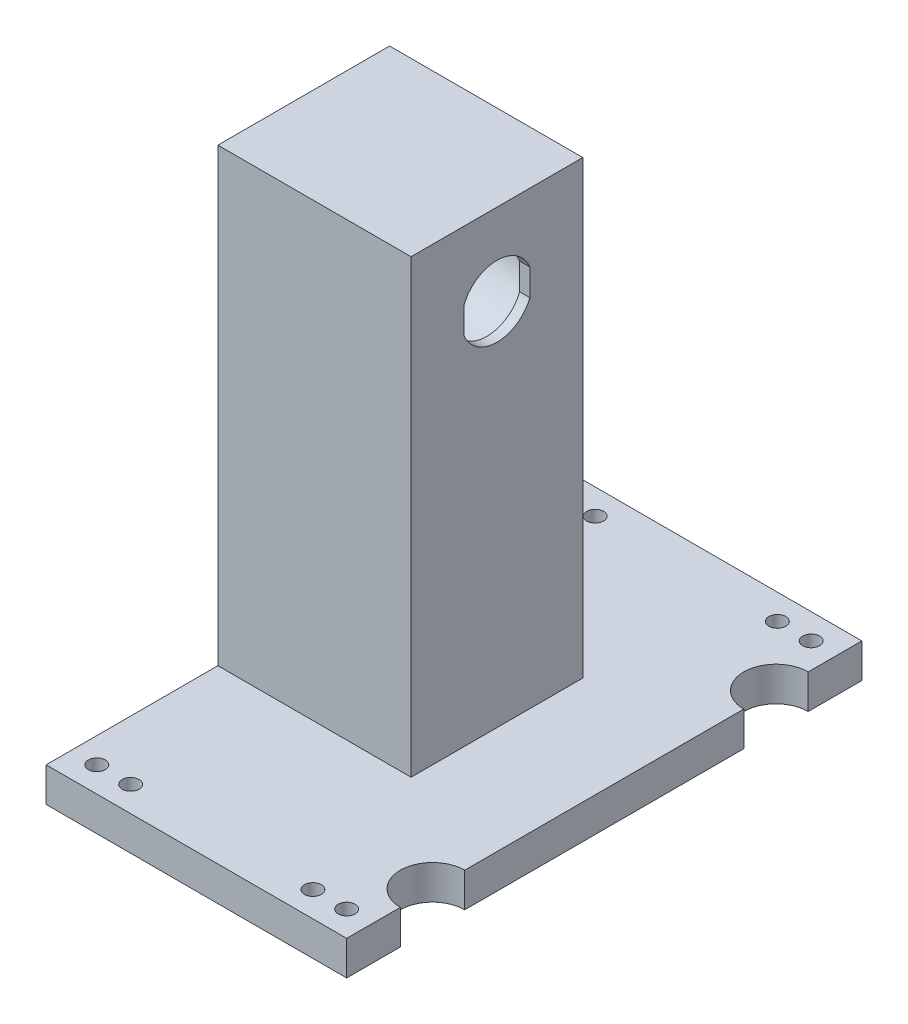
from build123d import *

# Parameters (mm, degrees)
SKETCH2_W           = 88.9
SKETCH2_H           = 152.4
BOSS_EXTRUDE1_DEPTH = 10.16
SKETCH5_W           = 57.15
SKETCH5_H           = 50.8
BOSS_EXTRUDE2_DEPTH = 133.35
SKETCH6_R           = 2.5
CUT_EXTRUDE1_DEPTH  = 11.16
SKETCH7_R           = 10.5
CUT_EXTRUDE2_DEPTH  = 58.15
SKETCH8_R           = 16.5
CUT_EXTRUDE3_DEPTH  = 54.15
SKETCH9_R           = 19.5
CUT_EXTRUDE4_DEPTH  = 16.51
BOSS_EXTRUDE3_DEPTH = 3
SKETCH12_R          = 9.525
CUT_EXTRUDE6_DEPTH  = 12.7


with BuildPart() as part:
    # Sketch2 → Boss-Extrude1 (new body)
    with BuildSketch(Plane(origin=(0, 0, 0), x_dir=(1, 0, 0), z_dir=(0, 1, 0))):
        with Locations((8.89, -19.614444444)):
            Rectangle(SKETCH2_W, SKETCH2_H)
    extrude(amount=BOSS_EXTRUDE1_DEPTH)

    # Sketch5 → Boss-Extrude2 (add)
    with BuildSketch(Plane(origin=(0, 10.16, 0), x_dir=(1, 0, 0), z_dir=(0, 1, 0))):
        with Locations((-6.985, -19.614444444)):
            Rectangle(SKETCH5_W, SKETCH5_H)
    extrude(amount=BOSS_EXTRUDE2_DEPTH)

    # Sketch6 → Cut-Extrude1 (cut, through all)
    with BuildSketch(Plane(origin=(0, 10.16, 0), x_dir=(1, 0, 0), z_dir=(0, 1, 0))):
        with Locations((35.84, -88.314444444)):
            Circle(SKETCH6_R)
        with Locations((45.84, -88.314444444)):
            Circle(SKETCH6_R)
        with Locations((-28.06, -88.314444444)):
            Circle(SKETCH6_R)
        with Locations((-18.06, -88.314444444)):
            Circle(SKETCH6_R)
        with Locations((-28.06, 49.085555556)):
            Circle(SKETCH6_R)
        with Locations((-18.06, 49.085555556)):
            Circle(SKETCH6_R)
        with Locations((35.84, 49.085555556)):
            Circle(SKETCH6_R)
        with Locations((45.84, 49.085555556)):
            Circle(SKETCH6_R)
    extrude(amount=-CUT_EXTRUDE1_DEPTH, mode=Mode.SUBTRACT)

    # Sketch7 → Cut-Extrude2 (cut, through all)
    with BuildSketch(Plane(origin=(21.59, 0, 0), x_dir=(0, 0, -1), z_dir=(1, 0, 0))):
        with Locations((-19.614444444, 119.38)):
            Circle(SKETCH7_R)
    extrude(amount=-CUT_EXTRUDE2_DEPTH, mode=Mode.SUBTRACT)

    # Sketch8 → Cut-Extrude3 (cut)
    with BuildSketch(Plane.ZY.offset(35.56)):
        with Locations((19.614444444, 119.38)):
            Circle(SKETCH8_R)
    extrude(amount=-CUT_EXTRUDE3_DEPTH, mode=Mode.SUBTRACT)

    # Sketch9 → Cut-Extrude4 (cut)
    with BuildSketch(Plane.ZY.offset(35.56)):
        with Locations((19.614444444, 119.38)):
            Circle(SKETCH9_R)
    extrude(amount=-CUT_EXTRUDE4_DEPTH, mode=Mode.SUBTRACT)

    # Sketch10 → Boss-Extrude3 (add)
    with BuildSketch(Plane(origin=(21.59, 0, 0), x_dir=(0, 0, -1), z_dir=(1, 0, 0))):
        with BuildLine():
            Line((-29.348407204, 123.317), (-29.348407204, 115.443))
            ThreePointArc((-29.348407204, 115.443), (-30.114444444, 119.38), (-29.348407204, 123.317))
        make_face()
        with BuildLine():
            Line((-9.880481685, 115.443), (-9.880481685, 123.317))
            ThreePointArc((-9.880481685, 123.317), (-9.114444444, 119.38), (-9.880481685, 115.443))
        make_face()
    extrude(amount=-BOSS_EXTRUDE3_DEPTH)

    # Sketch12 → Cut-Extrude6 (cut)
    with BuildSketch(Plane(origin=(0, 10.16, 0), x_dir=(1, 0, 0), z_dir=(0, 1, 0))):
        with Locations((53.34, -70.414444444)):
            Circle(SKETCH12_R)
        with Locations((53.34, 31.185555556)):
            Circle(SKETCH12_R)
    extrude(amount=-CUT_EXTRUDE6_DEPTH, mode=Mode.SUBTRACT)


solid = part.part
